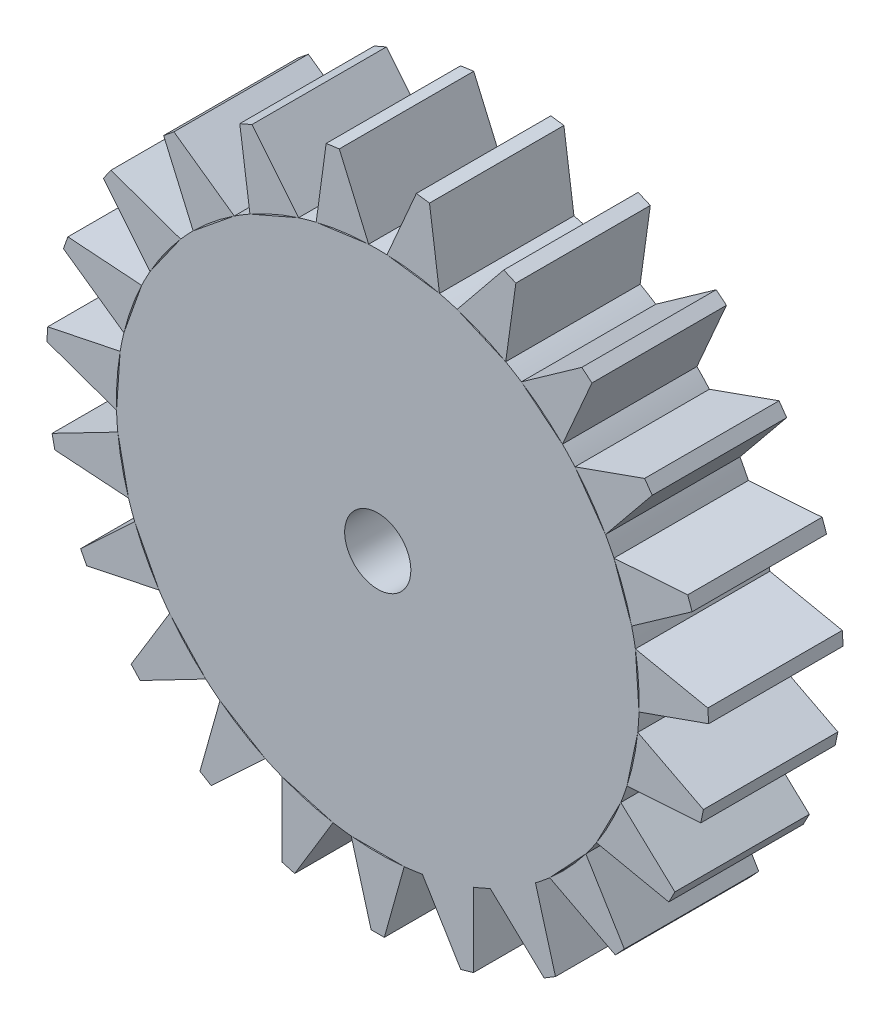
from build123d import *

# Parameters (mm, degrees)
BOSS_EXTRUDE1_DEPTH    = 10.16
SKETCH1_R              = 2.5
BOSS_EXTRUDE1_2_DEPTH  = 10.16
BOSS_EXTRUDE1_3_DEPTH  = 10.16
BOSS_EXTRUDE1_4_DEPTH  = 10.16
BOSS_EXTRUDE1_5_DEPTH  = 10.16
BOSS_EXTRUDE1_6_DEPTH  = 10.16
BOSS_EXTRUDE1_7_DEPTH  = 10.16
BOSS_EXTRUDE1_8_DEPTH  = 10.16
BOSS_EXTRUDE1_9_DEPTH  = 10.16
BOSS_EXTRUDE1_10_DEPTH = 10.16
BOSS_EXTRUDE1_11_DEPTH = 10.16
BOSS_EXTRUDE1_12_DEPTH = 10.16
BOSS_EXTRUDE1_13_DEPTH = 10.16
BOSS_EXTRUDE1_14_DEPTH = 10.16
BOSS_EXTRUDE1_15_DEPTH = 10.16
BOSS_EXTRUDE1_16_DEPTH = 10.16
BOSS_EXTRUDE1_17_DEPTH = 10.16
BOSS_EXTRUDE1_18_DEPTH = 10.16
BOSS_EXTRUDE1_19_DEPTH = 10.16
BOSS_EXTRUDE1_20_DEPTH = 10.16
BOSS_EXTRUDE1_21_DEPTH = 10.16
BOSS_EXTRUDE1_22_DEPTH = 10.16


with BuildPart() as part:
    # Sketch1 → Boss-Extrude1 (new body)
    with BuildSketch(Plane.XY):
        with BuildLine():
            Line((-2.005889355, -19.648709257), (-0.504104783, -25.031123873))
            Line((-0.504104783, -25.031123873), (0.495895217, -25.031123873))
            Line((0.495895217, -25.031123873), (1.997679788, -19.648709257))
            ThreePointArc((1.997679788, -19.648709257), (0, -19.75), (-1.997679788, -19.648709257))
            Line((-1.997679788, -19.648709257), (-2.005889355, -19.648709257))
        make_face()
    extrude(amount=BOSS_EXTRUDE1_DEPTH)


with BuildPart() as body_2:
    # Sketch1 → Boss-Extrude1 2 (new body)
    with BuildSketch(Plane.XY):
        with BuildLine():
            Line((-1.997679788, -19.648709257), (1.997679788, -19.648709257))
            ThreePointArc((1.997679788, -19.648709257), (2.68929132, -19.566047434), (3.377557912, -19.459049374))
            Line((3.377557912, -19.459049374), (3.369652778, -19.461264289))
            Line((3.369652778, -19.461264289), (6.267905189, -24.238907742))
            Line((6.267905189, -24.238907742), (7.230822476, -23.969110971))
            Line((7.230822476, -23.969110971), (7.224758718, -18.381114261))
            ThreePointArc((7.224758718, -18.381114261), (7.868421524, -18.114923205), (8.502297593, -17.826200819))
            Line((8.502297593, -17.826200819), (8.49528318, -17.830466378))
            Line((8.49528318, -17.830466378), (12.575053307, -21.649002709))
            Line((12.575053307, -21.649002709), (13.429472711, -21.129418759))
            Line((13.429472711, -21.129418759), (11.916010344, -15.750276108))
            ThreePointArc((11.916010344, -15.750276108), (12.4639869, -15.320297991), (12.996460758, -14.871264498))
            Line((12.996460758, -14.871264498), (15.723505995, -11.951312029))
            ThreePointArc((15.723505995, -11.951312029), (16.135155387, -11.389436362), (16.526735883, -10.813394521))
            Line((16.526735883, -10.813394521), (18.364861137, -7.26597381))
            ThreePointArc((18.364861137, -7.26597381), (18.609653212, -6.61387234), (18.831298612, -5.95354454))
            Line((18.831298612, -5.95354454), (19.644178542, -2.041751554))
            ThreePointArc((19.644178542, -2.041751554), (19.703958192, -1.347787664), (19.73923007, -0.652147397))
            Line((19.73923007, -0.652147397), (19.466577091, 3.333898075))
            ThreePointArc((19.466577091, 3.333898075), (19.336910732, 4.018256258), (19.183193136, 4.697616536))
            Line((19.183193136, 4.697616536), (17.84522867, 8.462287735))
            ThreePointArc((17.84522867, 8.462287735), (17.535733063, 9.086284495), (17.204426523, 9.69897974))
            Line((17.204426523, 9.69897974), (14.900381276, 12.963068226))
            ThreePointArc((14.900381276, 12.963068226), (14.434010294, 13.480424579), (13.949686301, 13.981013987))
            Line((13.949686301, 13.981013987), (10.850440766, 16.502437249))
            ThreePointArc((10.850440766, 16.502437249), (10.261783013, 16.87478324), (9.660361661, 17.226140386))
            Line((9.660361661, 17.226140386), (5.995772703, 18.817895995))
            ThreePointArc((5.995772703, 18.817895995), (5.32848623, 19.017616425), (4.65457219, 19.193682756))
            Line((4.65457219, 19.193682756), (0.696425607, 19.737717481))
            ThreePointArc((0.696425607, 19.737717481), (0, 19.75), (-0.696425607, 19.737717481))
            Line((-0.696425607, 19.737717481), (-4.65457219, 19.193682756))
            ThreePointArc((-4.65457219, 19.193682756), (-5.32848623, 19.017616425), (-5.995772703, 18.817895995))
            Line((-5.995772703, 18.817895995), (-9.660361661, 17.226140386))
            ThreePointArc((-9.660361661, 17.226140386), (-10.261783013, 16.87478324), (-10.850440766, 16.502437249))
            Line((-10.850440766, 16.502437249), (-13.949686301, 13.981013987))
            ThreePointArc((-13.949686301, 13.981013987), (-14.434010294, 13.480424579), (-14.900381276, 12.963068226))
            Line((-14.900381276, 12.963068226), (-17.204426523, 9.69897974))
            ThreePointArc((-17.204426523, 9.69897974), (-17.535733063, 9.086284495), (-17.84522867, 8.462287735))
            Line((-17.84522867, 8.462287735), (-19.183193136, 4.697616536))
            ThreePointArc((-19.183193136, 4.697616536), (-19.336910732, 4.018256258), (-19.466577091, 3.333898075))
            Line((-19.466577091, 3.333898075), (-19.73923007, -0.652147397))
            ThreePointArc((-19.73923007, -0.652147397), (-19.703958192, -1.347787664), (-19.644178542, -2.041751554))
            Line((-19.644178542, -2.041751554), (-18.831298612, -5.95354454))
            ThreePointArc((-18.831298612, -5.95354454), (-18.609653212, -6.61387234), (-18.364861137, -7.26597381))
            Line((-18.364861137, -7.26597381), (-16.526735883, -10.813394521))
            ThreePointArc((-16.526735883, -10.813394521), (-16.135155387, -11.389436362), (-15.723505995, -11.951312029))
            Line((-15.723505995, -11.951312029), (-12.996460758, -14.871264498))
            ThreePointArc((-12.996460758, -14.871264498), (-12.4639869, -15.320297991), (-11.916010344, -15.750276108))
            Line((-11.916010344, -15.750276108), (-8.502297593, -17.826200819))
            ThreePointArc((-8.502297593, -17.826200819), (-7.868421524, -18.114923205), (-7.224758718, -18.381114261))
            Line((-7.224758718, -18.381114261), (-3.377557912, -19.459049374))
            ThreePointArc((-3.377557912, -19.459049374), (-2.68929132, -19.566047434), (-1.997679788, -19.648709257))
        make_face()
        Circle(SKETCH1_R, mode=Mode.SUBTRACT)
    extrude(amount=BOSS_EXTRUDE1_2_DEPTH)


with BuildPart() as body_3:
    # Sketch1 → Boss-Extrude1 3 (new body)
    with BuildSketch(Plane.XY):
        with BuildLine():
            Line((-6.275810323, -24.236692827), (-3.377557912, -19.459049374))
            ThreePointArc((-3.377557912, -19.459049374), (-5.32848623, -19.017616425), (-7.224758718, -18.381114261))
            Line((-7.224758718, -18.381114261), (-7.232663852, -18.378899346))
            Line((-7.232663852, -18.378899346), (-7.23872761, -23.966896056))
            Line((-7.23872761, -23.966896056), (-6.275810323, -24.236692827))
        make_face()
    extrude(amount=BOSS_EXTRUDE1_3_DEPTH)


with BuildPart() as body_4:
    # Sketch1 → Boss-Extrude1 4 (new body)
    with BuildSketch(Plane.XY):
        with BuildLine():
            Line((-12.58206772, -21.64473715), (-8.502297593, -17.826200819))
            ThreePointArc((-8.502297593, -17.826200819), (-10.261783013, -16.87478324), (-11.916010344, -15.750276108))
            Line((-11.916010344, -15.750276108), (-11.923024757, -15.746010549))
            Line((-11.923024757, -15.746010549), (-13.436487125, -21.1251532))
            Line((-13.436487125, -21.1251532), (-12.58206772, -21.64473715))
        make_face()
    extrude(amount=BOSS_EXTRUDE1_4_DEPTH)


with BuildPart() as body_5:
    # Sketch1 → Boss-Extrude1 5 (new body)
    with BuildSketch(Plane.XY):
        with BuildLine():
            ThreePointArc((15.723505995, -11.951312029), (14.434010294, -13.480424579), (12.996460758, -14.871264498))
            Line((12.996460758, -14.871264498), (12.990857292, -14.877264345))
            Line((12.990857292, -14.877264345), (17.949567248, -17.453490183))
            Line((17.949567248, -17.453490183), (18.632120391, -16.722654219))
            Line((18.632120391, -16.722654219), (15.723505995, -11.951312029))
        make_face()
    extrude(amount=BOSS_EXTRUDE1_5_DEPTH)


with BuildPart() as body_6:
    # Sketch1 → Boss-Extrude1 6 (new body)
    with BuildSketch(Plane.XY):
        with BuildLine():
            Line((-17.955170714, -17.447490337), (-12.996460758, -14.871264498))
            ThreePointArc((-12.996460758, -14.871264498), (-14.434010294, -13.480424579), (-15.723505995, -11.951312029))
            Line((-15.723505995, -11.951312029), (-15.729109461, -11.945312182))
            Line((-15.729109461, -11.945312182), (-18.637723857, -16.716654372))
            Line((-18.637723857, -16.716654372), (-17.955170714, -17.447490337))
        make_face()
    extrude(amount=BOSS_EXTRUDE1_6_DEPTH)


with BuildPart() as body_7:
    # Sketch1 → Boss-Extrude1 7 (new body)
    with BuildSketch(Plane.XY):
        with BuildLine():
            ThreePointArc((18.364861137, -7.26597381), (17.535733063, -9.086284495), (16.526735883, -10.813394521))
            Line((16.526735883, -10.813394521), (16.522958948, -10.820683674))
            Line((16.522958948, -10.820683674), (21.992843901, -11.963532135))
            Line((21.992843901, -11.963532135), (22.452908938, -11.075646916))
            Line((22.452908938, -11.075646916), (18.364861137, -7.26597381))
        make_face()
    extrude(amount=BOSS_EXTRUDE1_7_DEPTH)


with BuildPart() as body_8:
    # Sketch1 → Boss-Extrude1 8 (new body)
    with BuildSketch(Plane.XY):
        with BuildLine():
            Line((-21.996620835, -11.956242982), (-16.526735883, -10.813394521))
            ThreePointArc((-16.526735883, -10.813394521), (-17.535733063, -9.086284495), (-18.364861137, -7.26597381))
            Line((-18.364861137, -7.26597381), (-18.368638072, -7.258684657))
            Line((-18.368638072, -7.258684657), (-22.456685873, -11.068357763))
            Line((-22.456685873, -11.068357763), (-21.996620835, -11.956242982))
        make_face()
    extrude(amount=BOSS_EXTRUDE1_8_DEPTH)


with BuildPart() as body_9:
    # Sketch1 → Boss-Extrude1 9 (new body)
    with BuildSketch(Plane.XY):
        with BuildLine():
            ThreePointArc((19.644178542, -2.041751554), (19.336910732, -4.018256258), (18.831298612, -5.95354454))
            Line((18.831298612, -5.95354454), (18.829628326, -5.961582396))
            Line((18.829628326, -5.961582396), (24.405011931, -5.586293637))
            Line((24.405011931, -5.586293637), (24.608467945, -4.60720955))
            Line((24.608467945, -4.60720955), (19.644178542, -2.041751554))
        make_face()
    extrude(amount=BOSS_EXTRUDE1_9_DEPTH)


with BuildPart() as body_10:
    # Sketch1 → Boss-Extrude1 10 (new body)
    with BuildSketch(Plane.XY):
        with BuildLine():
            Line((-24.406682217, -5.578255781), (-18.831298612, -5.95354454))
            ThreePointArc((-18.831298612, -5.95354454), (-19.336910732, -4.018256258), (-19.644178542, -2.041751554))
            Line((-19.644178542, -2.041751554), (-19.645848828, -2.033713698))
            Line((-19.645848828, -2.033713698), (-24.61013823, -4.599171693))
            Line((-24.61013823, -4.599171693), (-24.406682217, -5.578255781))
        make_face()
    extrude(amount=BOSS_EXTRUDE1_10_DEPTH)


with BuildPart() as body_11:
    # Sketch1 → Boss-Extrude1 11 (new body)
    with BuildSketch(Plane.XY):
        with BuildLine():
            ThreePointArc((19.466577091, 3.333898075), (19.703958192, 1.347787664), (19.73923007, -0.652147397))
            Line((19.73923007, -0.652147397), (19.739790311, -0.660337825))
            Line((19.739790311, -0.660337825), (25.007171873, 1.205254704))
            Line((25.007171873, 1.205254704), (24.938929459, 2.202923473))
            Line((24.938929459, 2.202923473), (19.466577091, 3.333898075))
        make_face()
    extrude(amount=BOSS_EXTRUDE1_11_DEPTH)


with BuildPart() as body_12:
    # Sketch1 → Boss-Extrude1 12 (new body)
    with BuildSketch(Plane.XY):
        with BuildLine():
            Line((-25.006611632, 1.213445132), (-19.73923007, -0.652147397))
            ThreePointArc((-19.73923007, -0.652147397), (-19.703958192, 1.347787664), (-19.466577091, 3.333898075))
            Line((-19.466577091, 3.333898075), (-19.46601685, 3.342088503))
            Line((-19.46601685, 3.342088503), (-24.938369219, 2.211113901))
            Line((-24.938369219, 2.211113901), (-25.006611632, 1.213445132))
        make_face()
    extrude(amount=BOSS_EXTRUDE1_12_DEPTH)


with BuildPart() as body_13:
    # Sketch1 → Boss-Extrude1 13 (new body)
    with BuildSketch(Plane.XY):
        with BuildLine():
            ThreePointArc((17.84522867, 8.462287735), (18.609653212, 6.61387234), (19.183193136, 4.697616536))
            Line((19.183193136, 4.697616536), (19.185942352, 4.689880982))
            Line((19.185942352, 4.689880982), (23.754664277, 7.907414817))
            Line((23.754664277, 7.907414817), (23.419784664, 8.849675739))
            Line((23.419784664, 8.849675739), (17.84522867, 8.462287735))
        make_face()
    extrude(amount=BOSS_EXTRUDE1_13_DEPTH)


with BuildPart() as body_14:
    # Sketch1 → Boss-Extrude1 14 (new body)
    with BuildSketch(Plane.XY):
        with BuildLine():
            Line((-23.75191506, 7.915150371), (-19.183193136, 4.697616536))
            ThreePointArc((-19.183193136, 4.697616536), (-18.609653212, 6.61387234), (-17.84522867, 8.462287735))
            Line((-17.84522867, 8.462287735), (-17.842479453, 8.470023289))
            Line((-17.842479453, 8.470023289), (-23.417035448, 8.857411293))
            Line((-23.417035448, 8.857411293), (-23.75191506, 7.915150371))
        make_face()
    extrude(amount=BOSS_EXTRUDE1_14_DEPTH)


with BuildPart() as body_15:
    # Sketch1 → Boss-Extrude1 15 (new body)
    with BuildSketch(Plane.XY):
        with BuildLine():
            ThreePointArc((14.900381276, 12.963068226), (16.135155387, 11.389436362), (17.204426523, 9.69897974))
            Line((17.204426523, 9.69897974), (17.209160819, 9.692272771))
            Line((17.209160819, 9.692272771), (20.740381901, 14.023118147))
            Line((20.740381901, 14.023118147), (20.163701579, 14.84008804))
            Line((20.163701579, 14.84008804), (14.900381276, 12.963068226))
        make_face()
    extrude(amount=BOSS_EXTRUDE1_15_DEPTH)


with BuildPart() as body_16:
    # Sketch1 → Boss-Extrude1 16 (new body)
    with BuildSketch(Plane.XY):
        with BuildLine():
            Line((-20.735647606, 14.029825116), (-17.204426523, 9.69897974))
            ThreePointArc((-17.204426523, 9.69897974), (-16.135155387, 11.389436362), (-14.900381276, 12.963068226))
            Line((-14.900381276, 12.963068226), (-14.89564698, 12.969775195))
            Line((-14.89564698, 12.969775195), (-20.158967284, 14.846795009))
            Line((-20.158967284, 14.846795009), (-20.735647606, 14.029825116))
        make_face()
    extrude(amount=BOSS_EXTRUDE1_16_DEPTH)


with BuildPart() as body_17:
    # Sketch1 → Boss-Extrude1 17 (new body)
    with BuildSketch(Plane.XY):
        with BuildLine():
            ThreePointArc((10.850440766, 16.502437249), (12.4639869, 15.320297991), (13.949686301, 13.981013987))
            Line((13.949686301, 13.981013987), (13.956054554, 13.975833029))
            Line((13.956054554, 13.975833029), (16.187880281, 19.098790956))
            Line((16.187880281, 19.098790956), (15.412168991, 19.7298789))
            Line((15.412168991, 19.7298789), (10.850440766, 16.502437249))
        make_face()
    extrude(amount=BOSS_EXTRUDE1_17_DEPTH)


with BuildPart() as body_18:
    # Sketch1 → Boss-Extrude1 18 (new body)
    with BuildSketch(Plane.XY):
        with BuildLine():
            Line((-16.181512028, 19.103971914), (-13.949686301, 13.981013987))
            ThreePointArc((-13.949686301, 13.981013987), (-12.4639869, 15.320297991), (-10.850440766, 16.502437249))
            Line((-10.850440766, 16.502437249), (-10.844072513, 16.507618208))
            Line((-10.844072513, 16.507618208), (-15.405800737, 19.735059859))
            Line((-15.405800737, 19.735059859), (-16.181512028, 19.103971914))
        make_face()
    extrude(amount=BOSS_EXTRUDE1_18_DEPTH)


with BuildPart() as body_19:
    # Sketch1 → Boss-Extrude1 19 (new body)
    with BuildSketch(Plane.XY):
        with BuildLine():
            ThreePointArc((5.995772703, 18.817895995), (7.868421524, 18.114923205), (9.660361661, 17.226140386))
            Line((9.660361661, 17.226140386), (9.667891568, 17.222869685))
            Line((9.667891568, 17.222869685), (10.434797636, 22.757993811))
            Line((10.434797636, 22.757993811), (9.517586334, 23.1563949))
            Line((9.517586334, 23.1563949), (5.995772703, 18.817895995))
        make_face()
    extrude(amount=BOSS_EXTRUDE1_19_DEPTH)


with BuildPart() as body_20:
    # Sketch1 → Boss-Extrude1 20 (new body)
    with BuildSketch(Plane.XY):
        with BuildLine():
            Line((-10.427267728, 22.761264511), (-9.660361661, 17.226140386))
            ThreePointArc((-9.660361661, 17.226140386), (-7.868421524, 18.114923205), (-5.995772703, 18.817895995))
            Line((-5.995772703, 18.817895995), (-5.988242796, 18.821166696))
            Line((-5.988242796, 18.821166696), (-9.510056427, 23.159665601))
            Line((-9.510056427, 23.159665601), (-10.427267728, 22.761264511))
        make_face()
    extrude(amount=BOSS_EXTRUDE1_20_DEPTH)


with BuildPart() as body_21:
    # Sketch1 → Boss-Extrude1 21 (new body)
    with BuildSketch(Plane.XY):
        with BuildLine():
            ThreePointArc((0.696425607, 19.737717481), (2.68929132, 19.566047434), (4.65457219, 19.193682756))
            Line((4.65457219, 19.193682756), (4.662705292, 19.192564887))
            Line((4.662705292, 19.192564887), (3.907813785, 24.729340375))
            Line((3.907813785, 24.729340375), (2.917127839, 24.865507024))
            Line((2.917127839, 24.865507024), (0.696425607, 19.737717481))
        make_face()
    extrude(amount=BOSS_EXTRUDE1_21_DEPTH)


with BuildPart() as body_22:
    # Sketch1 → Boss-Extrude1 22 (new body)
    with BuildSketch(Plane.XY):
        with BuildLine():
            Line((-3.899680683, 24.730458245), (-4.65457219, 19.193682756))
            ThreePointArc((-4.65457219, 19.193682756), (-2.68929132, 19.566047434), (-0.696425607, 19.737717481))
            Line((-0.696425607, 19.737717481), (-0.688292505, 19.738835351))
            Line((-0.688292505, 19.738835351), (-2.908994737, 24.866624894))
            Line((-2.908994737, 24.866624894), (-3.899680683, 24.730458245))
        make_face()
    extrude(amount=BOSS_EXTRUDE1_22_DEPTH)


solid = Compound([part.part, body_2.part, body_3.part, body_4.part, body_5.part, body_6.part, body_7.part, body_8.part, body_9.part, body_10.part, body_11.part, body_12.part, body_13.part, body_14.part, body_15.part, body_16.part, body_17.part, body_18.part, body_19.part, body_20.part, body_21.part, body_22.part])
